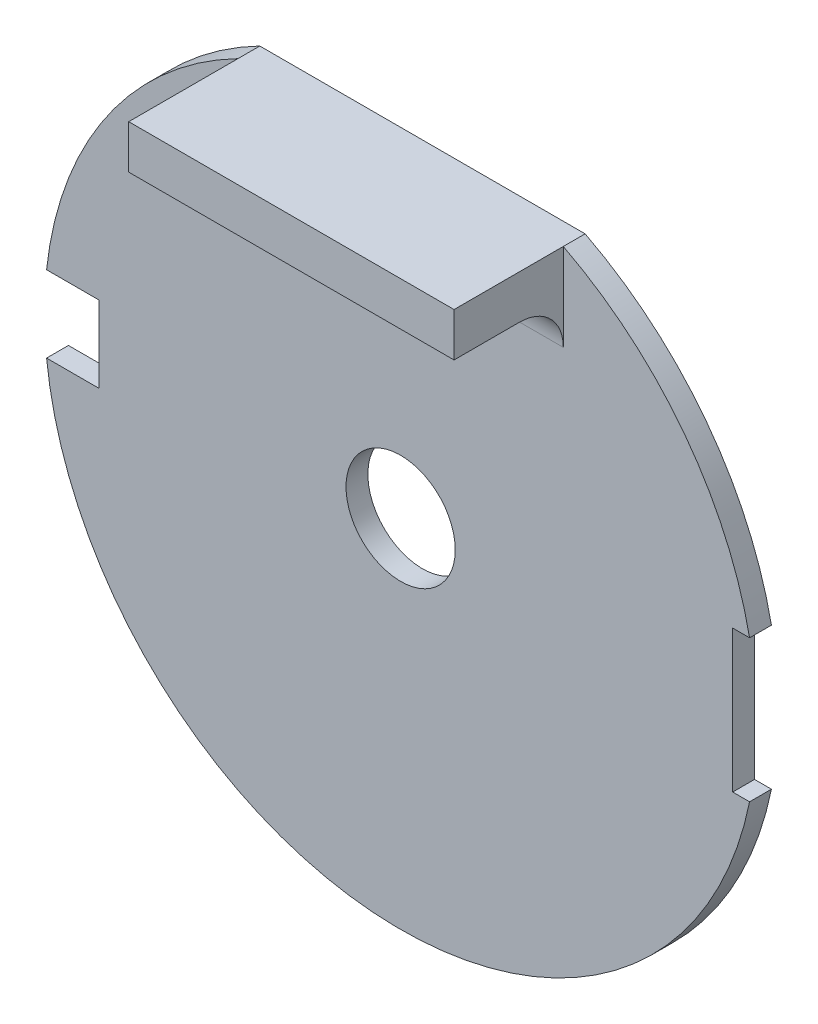
from build123d import *

# Parameters (mm, degrees)
SKETCH_1_R          = 2.5
EXTRUDE_1_DEPTH     = 1
SKETCH_2_W          = 5
SKETCH_2_H          = 3.5
SKETCH_2_W_2        = 2
SKETCH_2_H_2        = 6.5
CUT_EXTRUDE_1_DEPTH = 2
SKETCH_3_W          = 14.891608376
SKETCH_3_H          = 2
EXTRUDE_2_DEPTH     = 5
FILLET_1_R          = 2


with BuildPart() as part:
    # 草图1 → 凸台-拉伸1 (new body)
    with BuildSketch(Plane.XY):
        with BuildLine():
            Line((-7.445804188, 14.5), (7.445804188, 14.5))
            ThreePointArc((7.445804188, 14.5), (0, -16.3), (-7.445804188, 14.5))
        make_face()
        Circle(SKETCH_1_R, mode=Mode.SUBTRACT)
    extrude(amount=EXTRUDE_1_DEPTH)

    # 草图2 → 切除-拉伸1 (cut, through all)
    with BuildSketch(Plane.XY.offset(1)):
        with Locations((-16.3, 0)):
            Rectangle(SKETCH_2_W, SKETCH_2_H)
        with Locations((16.2, 0)):
            Rectangle(SKETCH_2_W_2, SKETCH_2_H_2)
    extrude(amount=-CUT_EXTRUDE_1_DEPTH, mode=Mode.SUBTRACT)

    # 草图3 → 凸台-拉伸2 (add)
    with BuildSketch(Plane.XY.offset(1)):
        with Locations((0, 13.5)):
            Rectangle(SKETCH_3_W, SKETCH_3_H)
    extrude(amount=EXTRUDE_2_DEPTH)

    # 圆角1
    fillet_1_edges = [part.edges().sort_by_distance(p)[0] for p in [
        (0, 12.5, 1),
    ]]
    fillet(fillet_1_edges, radius=FILLET_1_R)


solid = part.part
